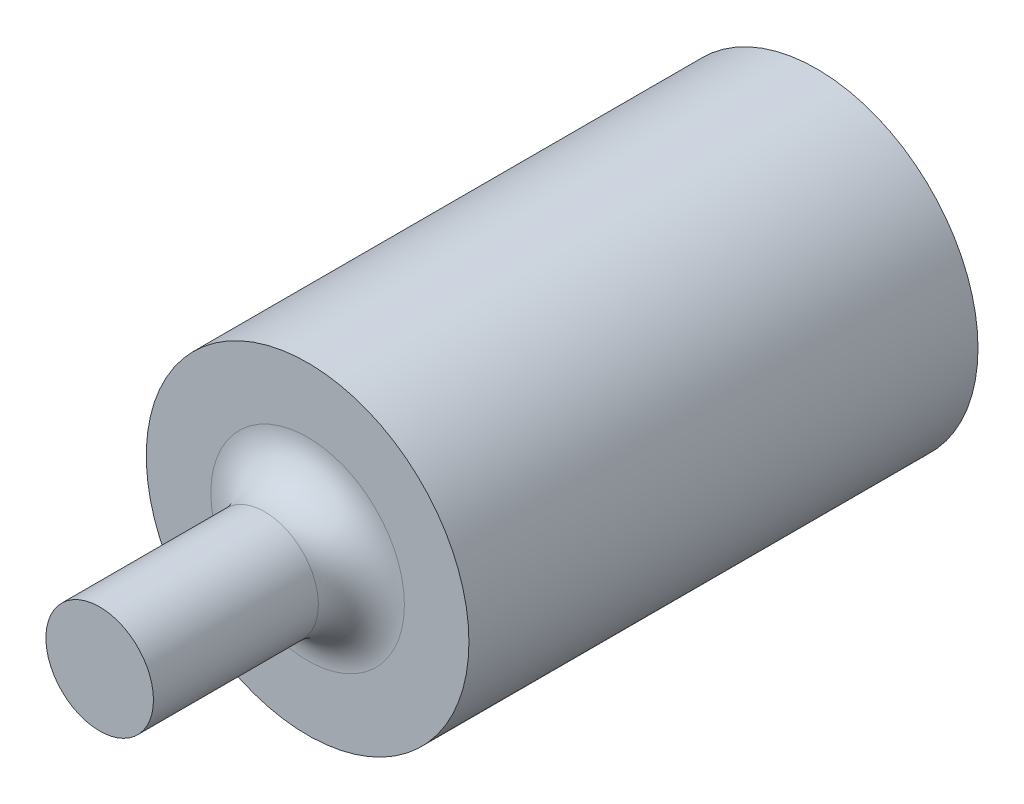
from build123d import *

# Parameters (mm, degrees)
SKETCH_1_R          = 11.25
EXTRUDE_1_DEPTH     = 35.5
SKETCH_2_R          = 3.75
EXTRUDE_2_DEPTH     = 14.5
FILLET_1_R          = 3
SKETCH_3_R          = 1.5
CUT_EXTRUDE_1_DEPTH = 10


with BuildPart() as part:
    # 草圖1 → 填料-伸長1 (new body)
    with BuildSketch(Plane.XY):
        Circle(SKETCH_1_R)
    extrude(amount=EXTRUDE_1_DEPTH)

    # 草圖2 → 填料-伸長2 (add)
    with BuildSketch(Plane.XY.offset(35.5)):
        Circle(SKETCH_2_R)
    extrude(amount=EXTRUDE_2_DEPTH)

    # 圓角1
    fillet_1_edges = [part.edges().sort_by_distance(p)[0] for p in [
        (-3.75, 0, 35.5),
    ]]
    fillet(fillet_1_edges, radius=FILLET_1_R)

    # 草圖3 → 除料-伸長1 (cut)
    with BuildSketch(Plane(origin=(0, 0, 0), x_dir=(-1, 0, 0), z_dir=(0, 0, -1))):
        with Locations((-8.5, 0)):
            Circle(SKETCH_3_R)
        with Locations((8.5, 0)):
            Circle(SKETCH_3_R)
        with Locations((0, -8.5)):
            Circle(SKETCH_3_R)
        with Locations((0, 8.5)):
            Circle(SKETCH_3_R)
    extrude(amount=-CUT_EXTRUDE_1_DEPTH, mode=Mode.SUBTRACT)


solid = part.part
